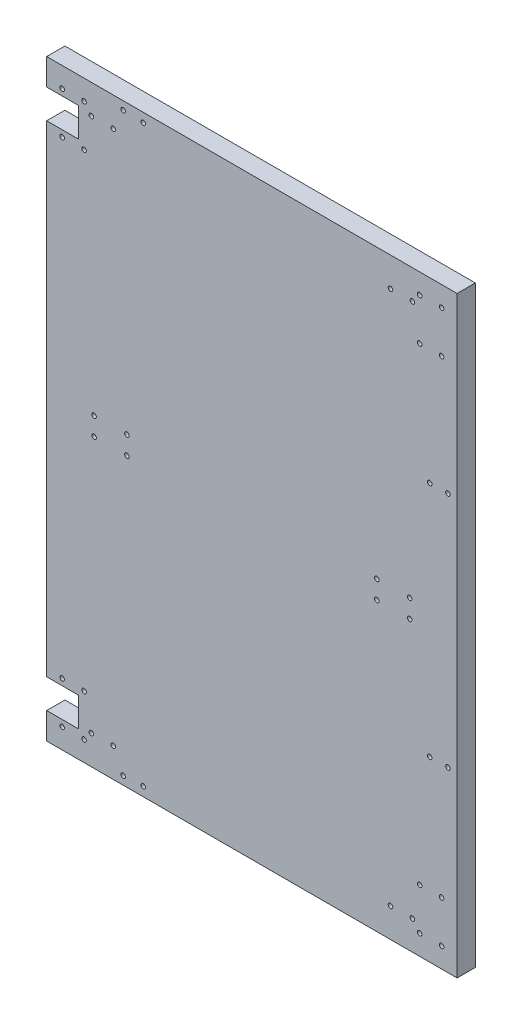
from build123d import *

# Parameters (mm, degrees)
SKETCH_1_W               = 450
SKETCH_1_H               = 650
EXTRUDE_1_DEPTH          = 20
SKETCH_2_R               = 2.5
CUT_EXTRUDE_1_DEPTH      = 21
SKETCH_3_R               = 2.5
CUT_EXTRUDE_2_DEPTH      = 21
SKETCH_4_R               = 2.5
CUT_EXTRUDE_3_DEPTH      = 21
SKETCH_5_R               = 2.5
CUT_EXTRUDE_4_DEPTH      = 21
MIRROR_6_COPY_1_SKETCH_R = 2.5
MIRROR_6_COPY_1_DEPTH    = 21
MIRROR_6_COPY_2_SKETCH_R = 2.5
MIRROR_6_COPY_2_DEPTH    = 21
CUT_EXTRUDE_START        = -21
CUT_EXTRUDE_5_DEPTH      = 22
SKETCH_7_R               = 2.5
CUT_EXTRUDE_6_DEPTH      = 21
SKETCH_9_R               = 2.5
CUT_EXTRUDE_7_DEPTH      = 21


with BuildPart() as part:
    # 草图1 → 凸台-拉伸1 (new body)
    with BuildSketch(Plane.XY):
        Rectangle(SKETCH_1_W, SKETCH_1_H)
    extrude(amount=EXTRUDE_1_DEPTH)

    # 草图2 → 切除-拉伸1 (cut, through all)
    with BuildSketch(Plane.XY.offset(20)):
        with Locations((137, 10)):
            Circle(SKETCH_2_R)
        with Locations((173, 10)):
            Circle(SKETCH_2_R)
        with Locations((137, -10)):
            Circle(SKETCH_2_R)
        with Locations((173, -10)):
            Circle(SKETCH_2_R)
    cut_extrude_1 = extrude(amount=-CUT_EXTRUDE_1_DEPTH, mode=Mode.SUBTRACT)

    # 草图3 → 切除-拉伸2 (cut, through all)
    with BuildSketch(Plane.XY.offset(20)):
        with Locations((152, -293)):
            Circle(SKETCH_3_R)
        with Locations((176, -293)):
            Circle(SKETCH_3_R)
    cut_extrude_2 = extrude(amount=-CUT_EXTRUDE_2_DEPTH, mode=Mode.SUBTRACT)

    # 草图4 → 切除-拉伸3 (cut, through all)
    with BuildSketch(Plane.XY.offset(20)):
        with Locations((184, -257)):
            Circle(SKETCH_4_R)
        with Locations((208, -257)):
            Circle(SKETCH_4_R)
        with Locations((184, -303)):
            Circle(SKETCH_4_R)
        with Locations((208, -303)):
            Circle(SKETCH_4_R)
    cut_extrude_3 = extrude(amount=-CUT_EXTRUDE_3_DEPTH, mode=Mode.SUBTRACT)

    # 草图5 → 切除-拉伸4 (cut, through all)
    with BuildSketch(Plane.XY.offset(20)):
        with Locations((195, -130)):
            Circle(SKETCH_5_R)
        with Locations((215, -130)):
            Circle(SKETCH_5_R)
        with Locations((195, 130)):
            Circle(SKETCH_5_R)
        with Locations((215, 130)):
            Circle(SKETCH_5_R)
    extrude(amount=-CUT_EXTRUDE_4_DEPTH, mode=Mode.SUBTRACT)

    # 镜向5: 切除-拉伸2, 切除-拉伸3 across plane
    add(cut_extrude_2.mirror(Plane.ZX), mode=Mode.SUBTRACT)
    add(cut_extrude_3.mirror(Plane.ZX), mode=Mode.SUBTRACT)

    # 镜向6: 切除-拉伸1, 切除-拉伸3, 切除-拉伸2 across plane
    add(cut_extrude_1.mirror(Plane(origin=(0, 0, 0), x_dir=(0, 0, 1), z_dir=(1, 0, 0))), mode=Mode.SUBTRACT)
    add(cut_extrude_3.mirror(Plane(origin=(0, 0, 0), x_dir=(0, 0, 1), z_dir=(1, 0, 0))), mode=Mode.SUBTRACT)
    add(cut_extrude_2.mirror(Plane(origin=(0, 0, 0), x_dir=(0, 0, 1), z_dir=(1, 0, 0))), mode=Mode.SUBTRACT)

    # 镜向6 copy 1 sketch → 镜向6 copy 1 (cut, through all)
    with BuildSketch(Plane(origin=(0, 0, 20), x_dir=(-1, 0, 0), z_dir=(0, 0, 1))):
        with Locations((152, -293)):
            Circle(MIRROR_6_COPY_1_SKETCH_R)
        with Locations((176, -293)):
            Circle(MIRROR_6_COPY_1_SKETCH_R)
    extrude(amount=-MIRROR_6_COPY_1_DEPTH, mode=Mode.SUBTRACT)

    # 镜向6 copy 2 sketch → 镜向6 copy 2 (cut, through all)
    with BuildSketch(Plane(origin=(0, 0, 20), x_dir=(-1, 0, 0), z_dir=(0, 0, 1))):
        with Locations((184, -257)):
            Circle(MIRROR_6_COPY_2_SKETCH_R)
        with Locations((208, -257)):
            Circle(MIRROR_6_COPY_2_SKETCH_R)
        with Locations((184, -303)):
            Circle(MIRROR_6_COPY_2_SKETCH_R)
        with Locations((208, -303)):
            Circle(MIRROR_6_COPY_2_SKETCH_R)
    extrude(amount=-MIRROR_6_COPY_2_DEPTH, mode=Mode.SUBTRACT)

    # 草图6 → 切除-拉伸5 (cut)
    with BuildSketch(Plane.XY.offset(20).offset(CUT_EXTRUDE_START)):
        Polygon((-1768.80702828, -264), (-225, -264), (-190, -264), (-190, -296), (-225, -296), (-1768.80702828, -296), (-4856.421084839, -296), (-4856.421084839, -264), align=None)
    cut_extrude_5 = extrude(amount=CUT_EXTRUDE_5_DEPTH, mode=Mode.SUBTRACT)

    # 镜向7: 切除-拉伸5 across plane
    add(cut_extrude_5.mirror(Plane.ZX), mode=Mode.SUBTRACT)

    # 草图7 → 切除-拉伸6 (cut, through all)
    with BuildSketch(Plane.XY.offset(20)):
        with Locations((-119.121080042, -315)):
            Circle(SKETCH_7_R)
    cut_extrude_6 = extrude(amount=-CUT_EXTRUDE_6_DEPTH, mode=Mode.SUBTRACT)

    # 镜向8: 切除-拉伸6 across plane
    add(cut_extrude_6.mirror(Plane.ZX), mode=Mode.SUBTRACT)

    # 草图9 → 切除-拉伸7 (cut, through all)
    with BuildSketch(Plane.XY.offset(20)):
        with Locations((-141.112070247, -315.945303472)):
            Circle(SKETCH_9_R)
    cut_extrude_7 = extrude(amount=-CUT_EXTRUDE_7_DEPTH, mode=Mode.SUBTRACT)

    # 镜向9: 切除-拉伸7 across plane
    add(cut_extrude_7.mirror(Plane.ZX), mode=Mode.SUBTRACT)


solid = part.part
